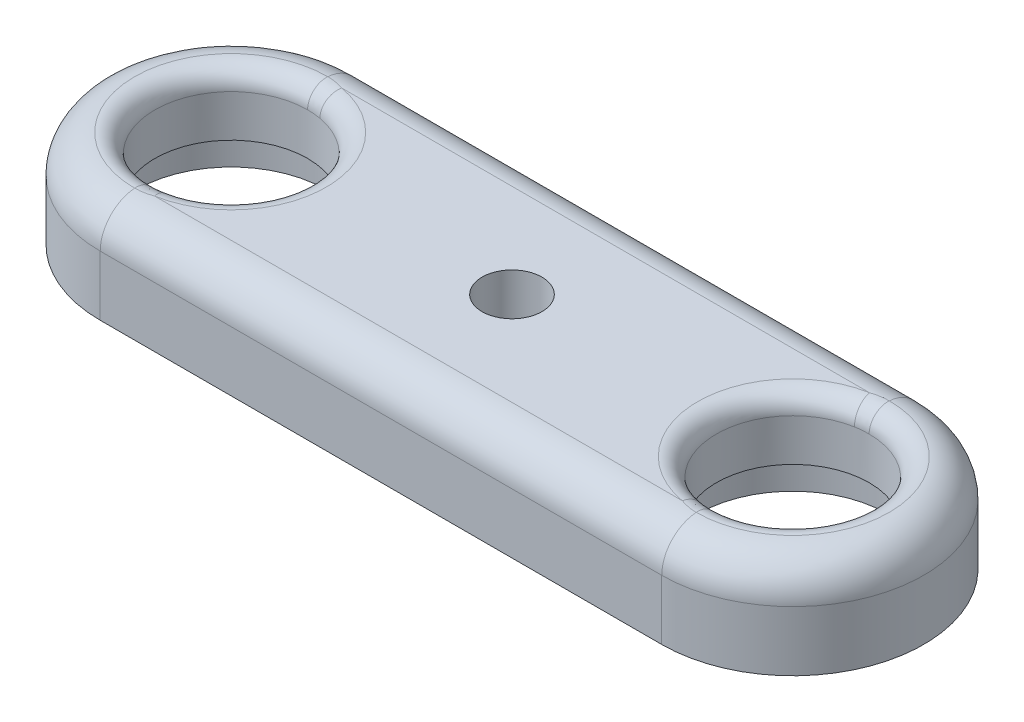
from build123d import *

# Parameters (mm, degrees)
SKETCH1_R           = 4.08
BOSS_EXTRUDE1_DEPTH = 5.2
SKETCH2_R           = 1.6
CUT_EXTRUDE1_DEPTH  = 5.2
SKETCH3_R           = 5.08
CUT_EXTRUDE2_DEPTH  = 1.95
FILLET1_R           = 2
FILLET2_R           = 1


with BuildPart() as part:
    # Sketch1 → Boss-Extrude1 (new body)
    with BuildSketch(Plane(origin=(0, 0, 0), x_dir=(1, 0, 0), z_dir=(0, 1, 0))):
        with BuildLine():
            Line((-15, 7), (15, 7))
            ThreePointArc((15, 7), (22, 0), (15, -7))
            Line((15, -7), (-15, -7))
            ThreePointArc((-15, -7), (-22, 0), (-15, 7))
        make_face()
        with Locations((-15, 0)):
            Circle(SKETCH1_R, mode=Mode.SUBTRACT)
        with Locations((15, 0)):
            Circle(SKETCH1_R, mode=Mode.SUBTRACT)
    extrude(amount=BOSS_EXTRUDE1_DEPTH)

    # Sketch2 → Cut-Extrude1 (cut)
    with BuildSketch(Plane(origin=(0, 5.2, 0), x_dir=(1, 0, 0), z_dir=(0, 1, 0))):
        Circle(SKETCH2_R)
    extrude(amount=-CUT_EXTRUDE1_DEPTH, mode=Mode.SUBTRACT)

    # Sketch3 → Cut-Extrude2 (cut)
    with BuildSketch(Plane.XZ):
        with Locations((-15, 0)):
            Circle(SKETCH3_R)
        with Locations((15, 0)):
            Circle(SKETCH3_R)
    extrude(amount=-CUT_EXTRUDE2_DEPTH, mode=Mode.SUBTRACT)

    # Fillet1
    fillet1_edges = [part.edges().sort_by_distance(p)[0] for p in [
        (22, 5.2, 0),
        (0, 5.2, -7),
        (-22, 5.2, 0),
        (0, 5.2, 7),
    ]]
    fillet(fillet1_edges, radius=FILLET1_R)

    # Fillet2
    fillet2_edges = [part.edges().sort_by_distance(p)[0] for p in [
        (10.92, 5.2, 0),
        (-19.08, 5.2, 0),
    ]]
    fillet(fillet2_edges, radius=FILLET2_R)


solid = part.part
